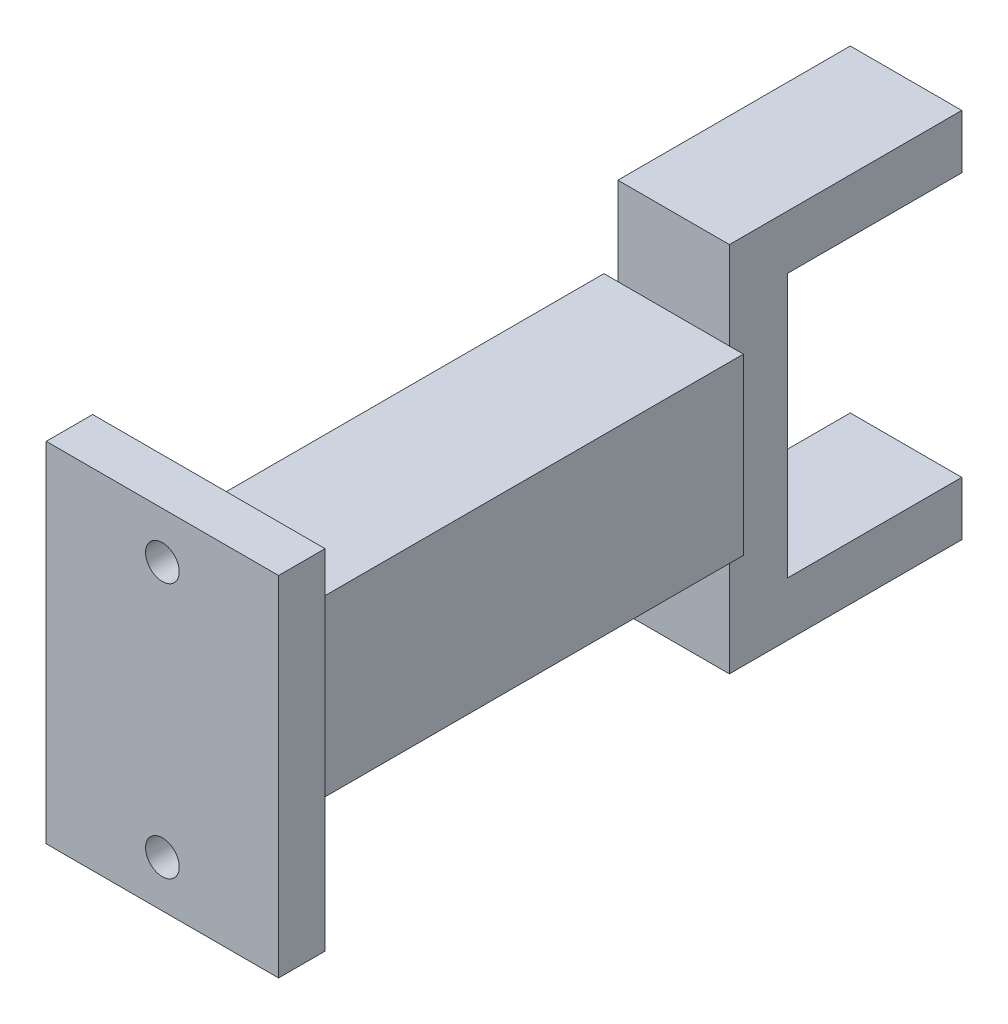
from build123d import *

# Parameters (mm, degrees)
SKETCH_1_W          = 20
SKETCH_1_H          = 30
SKETCH_1_R          = 1.45
EXTRUDE_1_DEPTH     = 4
SKETCH_2_W          = 12
SKETCH_2_H          = 15
EXTRUDE_2_DEPTH     = 40
SKETCH_3_W          = 9.6
SKETCH_3_H          = 32
EXTRUDE_3_DEPTH     = 20
SKETCH_4_W          = 9.6
SKETCH_4_H          = 22.7
EXTRUDE_4_DEPTH     = 15
SKETCH_4_2_W        = 9.6
SKETCH_4_2_H        = 22.7
CUT_EXTRUDE_1_DEPTH = 15


with BuildPart() as part:
    # Эскиз1 → Бобышка-Вытянуть1 (new body)
    with BuildSketch(Plane.XY):
        with Locations((-1.805054152, 0.992779783)):
            Rectangle(SKETCH_1_W, SKETCH_1_H)
        with Locations((-1.805054152, 11.992779783)):
            Circle(SKETCH_1_R, mode=Mode.SUBTRACT)
        with Locations((-1.805054152, -10.007220217)):
            Circle(SKETCH_1_R, mode=Mode.SUBTRACT)
    extrude(amount=EXTRUDE_1_DEPTH)

    # Эскиз2 → Бобышка-Вытянуть2 (add)
    with BuildSketch(Plane(origin=(0, 0, 0), x_dir=(-1, 0, 0), z_dir=(0, 0, -1))):
        with Locations((1.805054152, 0.992779783)):
            Rectangle(SKETCH_2_W, SKETCH_2_H)
    extrude(amount=EXTRUDE_2_DEPTH)

    # Эскиз3 → Бобышка-Вытянуть3 (add)
    with BuildSketch(Plane(origin=(0, 0, -40), x_dir=(-1, 0, 0), z_dir=(0, 0, -1))):
        with Locations((1.805054152, 0.05753703)):
            Rectangle(SKETCH_3_W, SKETCH_3_H)
    extrude(amount=EXTRUDE_3_DEPTH)

    # Эскиз4 → Бобышка-Вытянуть4 (add)
    with BuildSketch(Plane(origin=(0, 0, -60), x_dir=(-1, 0, 0), z_dir=(0, 0, -1))):
        with Locations((1.805054152, 0.05753703)):
            Rectangle(SKETCH_4_W, SKETCH_4_H)
    extrude(amount=-EXTRUDE_4_DEPTH)

    # Эскиз4<2> → Вырез-Вытянуть1 (cut)
    with BuildSketch(Plane(origin=(0, 0, -60), x_dir=(-1, 0, 0), z_dir=(0, 0, -1))):
        with Locations((1.805054152, 0.05753703)):
            Rectangle(SKETCH_4_2_W, SKETCH_4_2_H)
    extrude(amount=-CUT_EXTRUDE_1_DEPTH, mode=Mode.SUBTRACT)


solid = part.part
